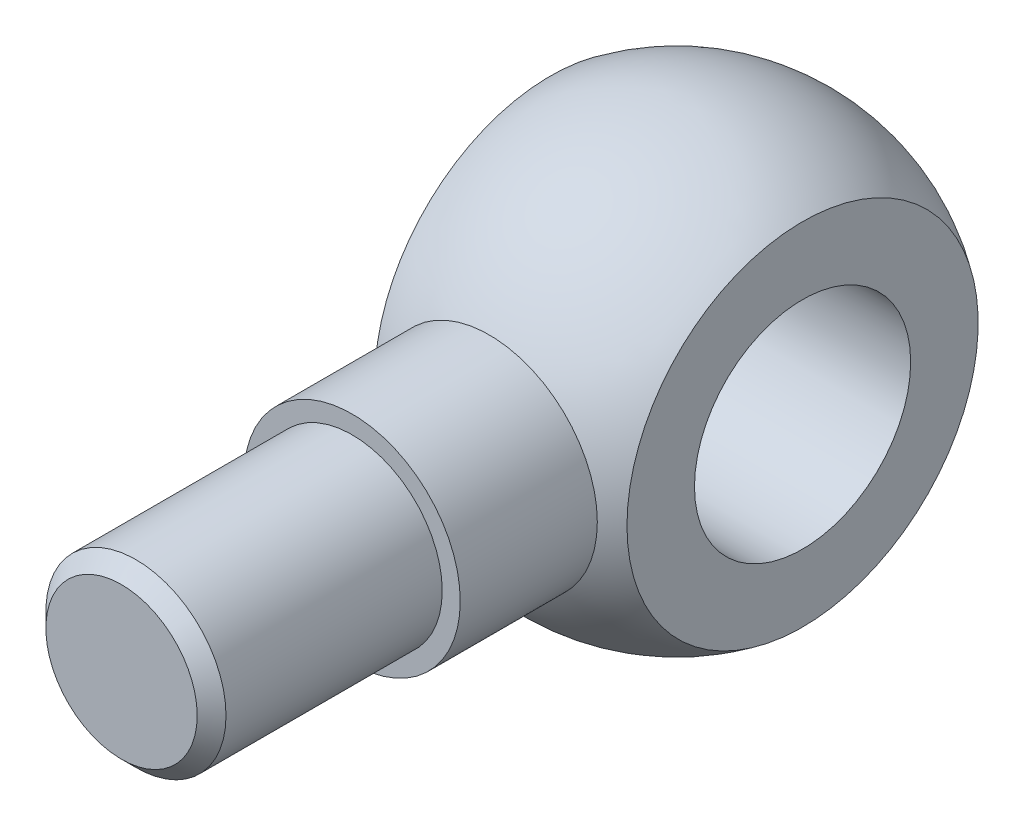
from build123d import *

# Parameters (mm, degrees)
P_IDAT_VYSUNUT_M1_REACH = 77
SKICA4_R                = 15
SKICA5_R                = 12.5
P_IDAT_VYSUNUT_M2_DEPTH = 32
ZKOSEN_1_SIZE           = 2


with BuildPart() as part:
    # Skica1 → Rotovat1 (revolve)
    with BuildSketch(Plane.XY):
        with BuildLine():
            ThreePointArc((17.5, 24.366985862), (0, 30), (-17.5, 24.366985862))
            Line((-17.5, 24.366985862), (-17.5, 15))
            Line((-17.5, 15), (17.5, 15))
            Line((17.5, 15), (17.5, 24.366985862))
        make_face()
    revolve(axis=Axis((-37.473333333, 0, 0), (1, 0, 0)))

    # Skica4 → Přidat vysunutím1 (add, up to next)
    with BuildSketch(Plane.XY.offset(45), mode=Mode.PRIVATE) as p_idat_vysunut_m1_sk1:
        Circle(SKICA4_R)
    p_idat_vysunut_m1_tool1 = extrude(p_idat_vysunut_m1_sk1.sketch, amount=-P_IDAT_VYSUNUT_M1_REACH, mode=Mode.PRIVATE) - part.part
    add(p_idat_vysunut_m1_tool1.solids().sort_by_distance((0, 0, 45))[0])

    # Skica5 → Přidat vysunutím2 (add)
    with BuildSketch(Plane.XY.offset(45)):
        Circle(SKICA5_R)
    extrude(amount=P_IDAT_VYSUNUT_M2_DEPTH)

    # Zkosení1
    zkosen_1_edges = [part.edges().sort_by_distance(p)[0] for p in [
        (-12.5, 0, 77),
    ]]
    chamfer(zkosen_1_edges, length=ZKOSEN_1_SIZE)


solid = part.part
